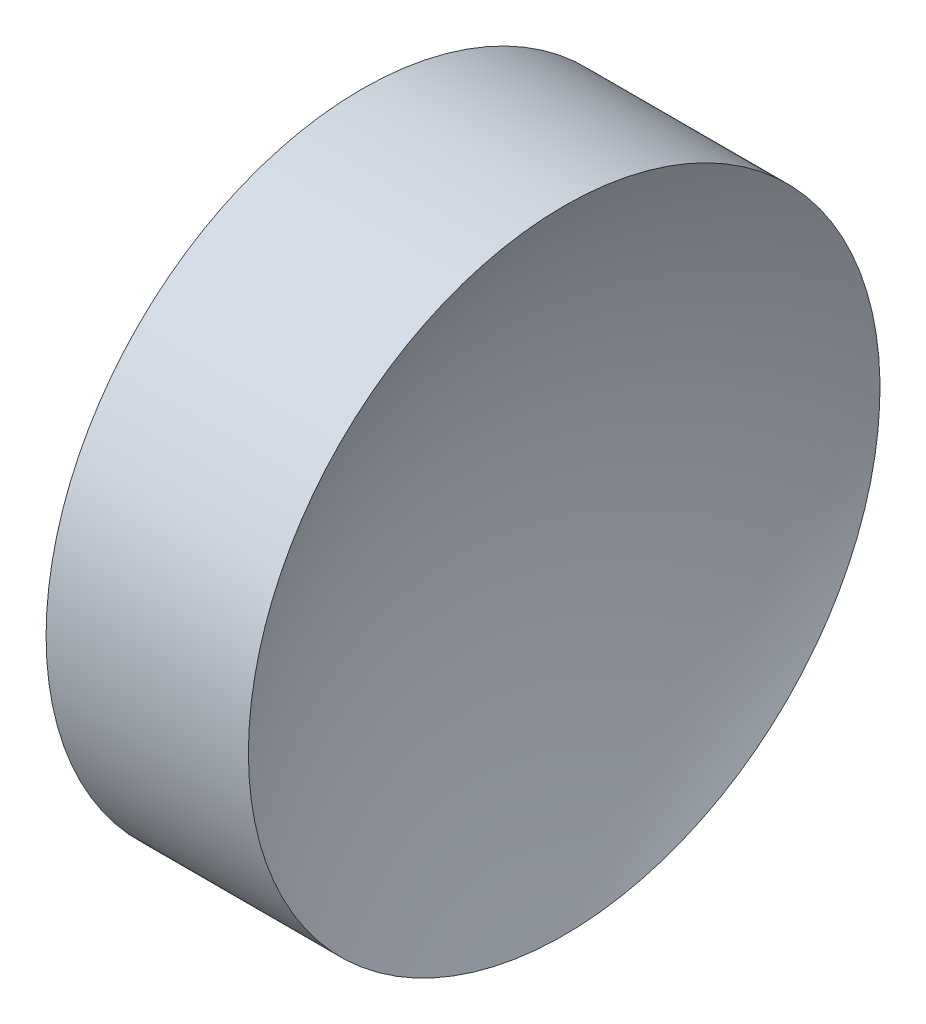
from build123d import *


with BuildPart() as part:
    # 草图1 → 旋转1 (revolve)
    with BuildSketch(Plane.XY):
        with BuildLine():
            Line((121.102703446, 65.222602873), (119.102703446, 65.222602873))
            ThreePointArc((119.102703446, 65.222602873), (118.324833018, 71.755261462), (116.034721546, 77.922602873))
            Line((116.034721546, 77.922602873), (120.102703446, 77.922602873))
            Line((120.102703446, 77.922602873), (124.170685347, 77.922602873))
            ThreePointArc((124.170685347, 77.922602873), (121.880573875, 71.755261462), (121.102703446, 65.222602873))
        make_face()
    revolve(axis=Axis((112.241463295, 65.222602873, 0), (1, 0, 0)))


solid = part.part
